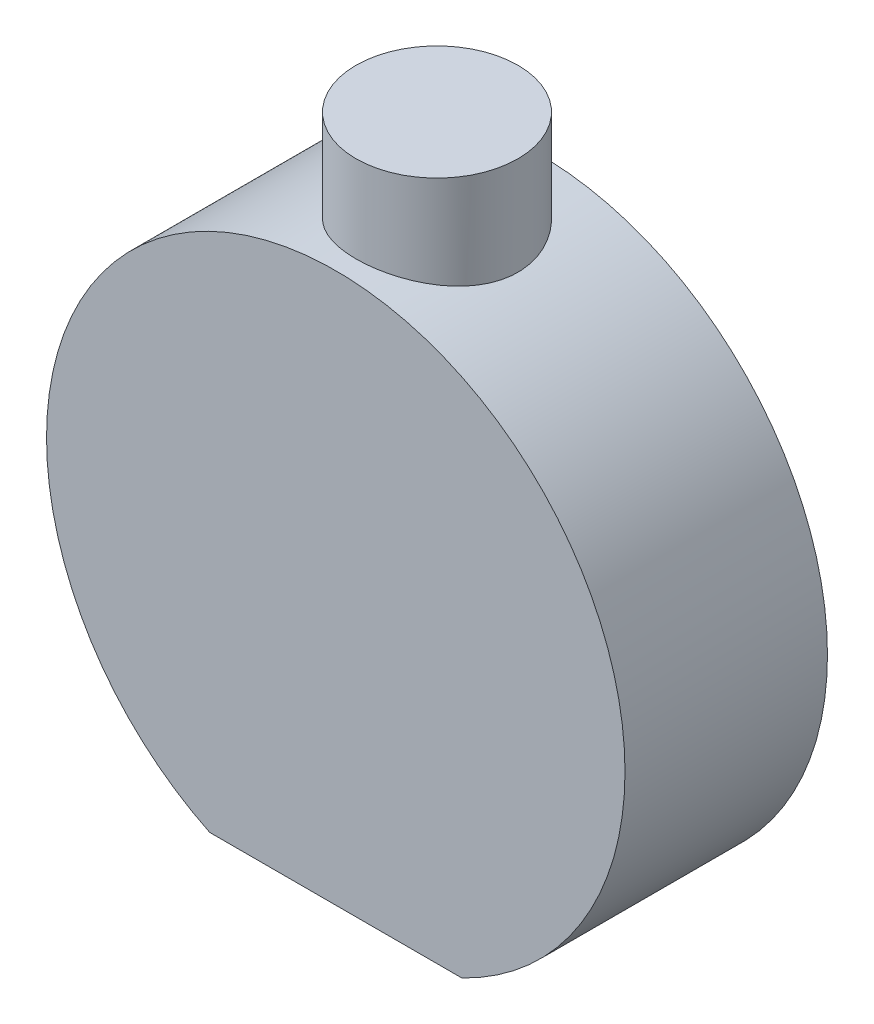
from build123d import *

# Parameters (mm, degrees)
SKETCH_1_R          = 50
EXTRUDE_1_DEPTH     = 35
SKETCH_2_R          = 14
EXTRUDE_2_DEPTH     = 65
CUT_EXTRUDE_START   = -110
SKETCH_3_W          = 150
SKETCH_3_H          = 100
CUT_EXTRUDE_1_DEPTH = 64


with BuildPart() as part:
    # 草图1 → 凸台-拉伸1 (new body)
    with BuildSketch(Plane.XY):
        Circle(SKETCH_1_R)
    extrude(amount=EXTRUDE_1_DEPTH)

    # 草图2 → 凸台-拉伸2 (add)
    with BuildSketch(Plane(origin=(0, 0, 0), x_dir=(1, 0, 0), z_dir=(0, 1, 0))):
        with Locations((0, -17.5)):
            Circle(SKETCH_2_R)
    extrude(amount=EXTRUDE_2_DEPTH)

    # 草图3 → 切除-拉伸1 (cut)
    with BuildSketch(Plane(origin=(0, 65, 0), x_dir=(1, 0, 0), z_dir=(0, 1, 0)).offset(CUT_EXTRUDE_START)):
        Rectangle(SKETCH_3_W, SKETCH_3_H)
    extrude(amount=-CUT_EXTRUDE_1_DEPTH, mode=Mode.SUBTRACT)


solid = part.part
